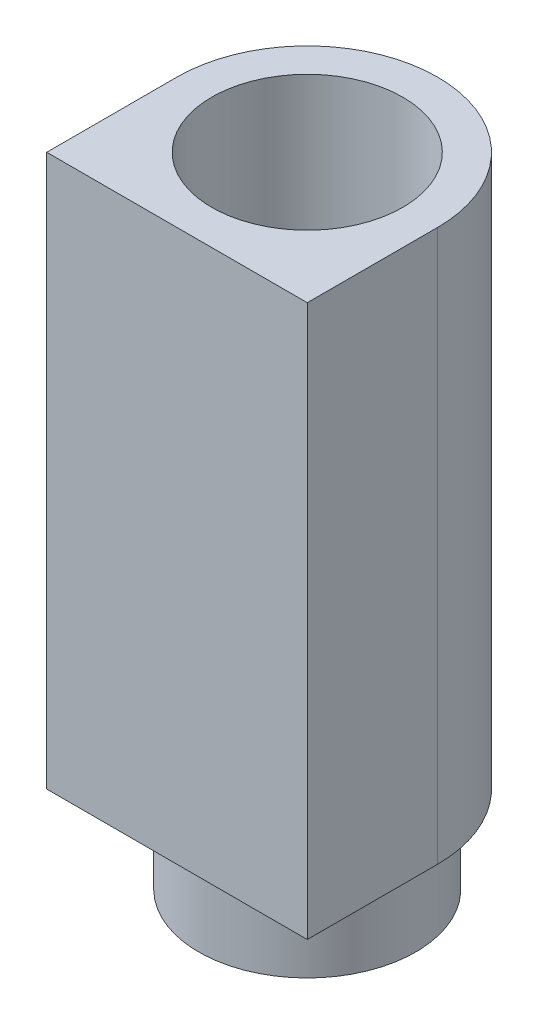
from build123d import *

# Parameters (mm, degrees)
BOSS_EXTRUDE1_DEPTH = 127
SKETCH3_R           = 25
BOSS_EXTRUDE2_DEPTH = 20
SKETCH4_R           = 22
CUT_EXTRUDE2_DEPTH  = 148


with BuildPart() as part:
    # Sketch1 → Boss-Extrude1 (new body)
    with BuildSketch(Plane(origin=(0, 0, 0), x_dir=(1, 0, 0), z_dir=(0, 1, 0))):
        with BuildLine():
            Line((-30, 0), (-30, -30))
            Line((-30, -30), (30, -30))
            Line((30, -30), (30, 0))
            ThreePointArc((30, 0), (0, 30), (-30, 0))
        make_face()
    extrude(amount=BOSS_EXTRUDE1_DEPTH)

    # Sketch3 → Boss-Extrude2 (add)
    with BuildSketch(Plane(origin=(0, 0, 0), x_dir=(-1, 0, 0), z_dir=(0, -1, 0))):
        Circle(SKETCH3_R)
    extrude(amount=BOSS_EXTRUDE2_DEPTH)

    # Sketch4 → Cut-Extrude2 (cut, through all)
    with BuildSketch(Plane(origin=(0, -20, 0), x_dir=(-1, 0, 0), z_dir=(0, -1, 0))):
        Circle(SKETCH4_R)
    extrude(amount=-CUT_EXTRUDE2_DEPTH, mode=Mode.SUBTRACT)


solid = part.part
